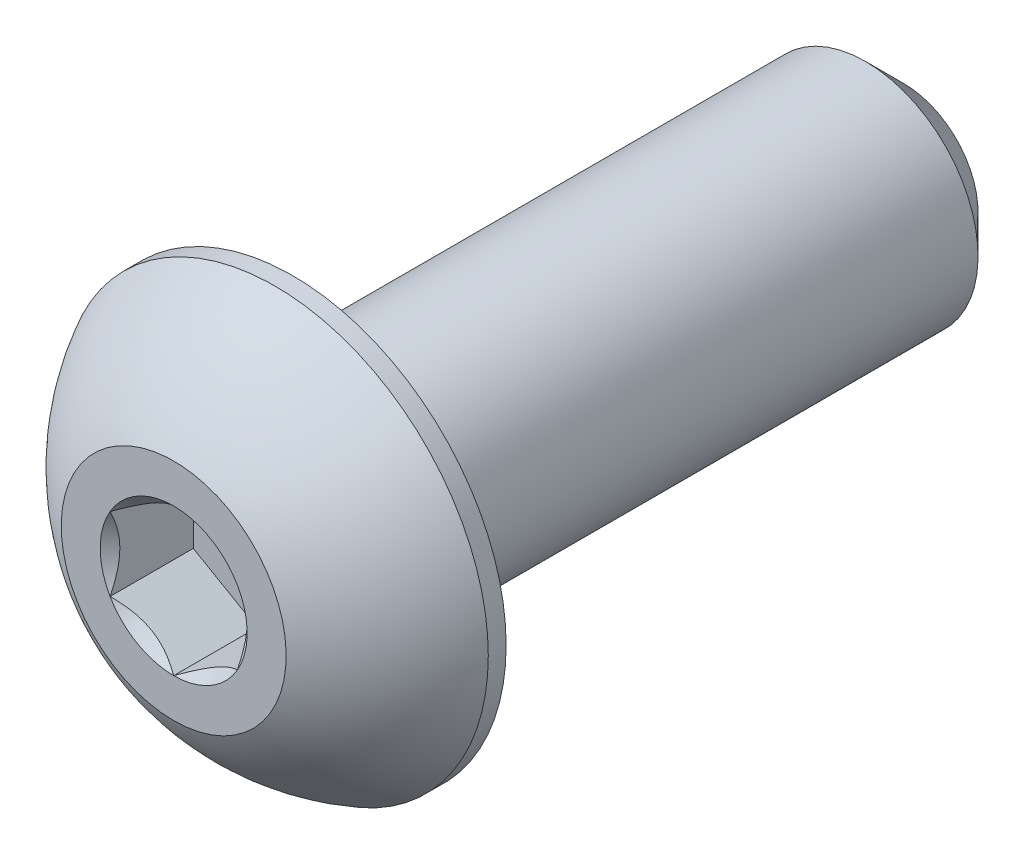
from build123d import *

# Parameters (mm, degrees)
SKETCH1_W          = 9.525
SKETCH1_H          = 1.7526
CHAMFER1_SIZE      = 0.5953125
CUT_EXTRUDE2_DEPTH = 1.29794


with BuildPart() as part:
    # Sketch1 → Revolve1 (revolve)
    with BuildSketch(Plane(origin=(0, 0, 0), x_dir=(0, 0, -1), z_dir=(1, 0, 0))):
        with Locations((6.6167, 0.8763)):
            Rectangle(SKETCH1_W, SKETCH1_H)
    revolve(axis=Axis((0, 0, -11.3792), (0, 0, 1)))

    # Chamfer1
    chamfer1_edges = [part.edges().sort_by_distance(p)[0] for p in [
        (0, -1.7526, -11.3792),
    ]]
    chamfer(chamfer1_edges, length=CHAMFER1_SIZE)

    # Sketch7 → Revolve2 (revolve)
    with BuildSketch(Plane(origin=(0, 0, 0), x_dir=(0, 0, -1), z_dir=(1, 0, 0))):
        with BuildLine():
            Line((1.57607, 3.3274), (1.8542, 3.3274))
            Line((1.8542, 3.3274), (1.8542, 0))
            Line((1.8542, 0), (0, 0))
            Line((0, 0), (0, 1.7526))
            ThreePointArc((0, 1.7526), (0.668695369, 2.659435873), (1.57607, 3.3274))
        make_face()
    revolve(axis=Axis((0, 0, 0), (0, 0, -1)))

    # Sketch5 → Cut-Extrude2 (cut)
    with BuildSketch(Plane.XY):
        Polygon((0.9921875, -0.57283972), (0.9921875, 0.57283972), (0, 1.14567944), (-0.9921875, 0.57283972), (-0.9921875, -0.57283972), (0, -1.14567944), align=None)
    extrude(amount=-CUT_EXTRUDE2_DEPTH, mode=Mode.SUBTRACT)

    # Cut-Extrude3 cone 1 section (through the dimple's axis) → Cut-Extrude3 (revolve, cut)
    with BuildSketch(Plane(origin=(0, 0, 0), x_dir=(0, -1, 0), z_dir=(1, 0, 0))):
        Polygon((0, 0), (1.14567944, 0), (0, 1.14567944), align=None)
    revolve(axis=Axis((0, 0, 0), (0, 0, -1)), mode=Mode.SUBTRACT)


solid = part.part
